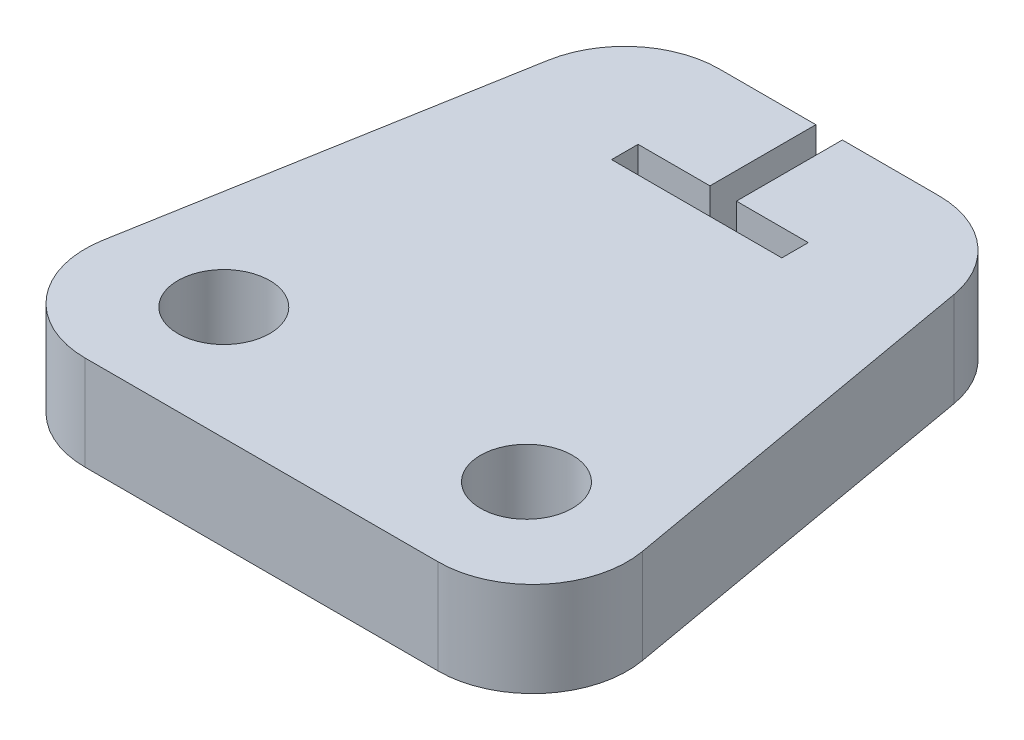
from build123d import *

# Parameters (mm, degrees)
BOSS_EXTRUDE1_DEPTH = 6.35
SKETCH2_R           = 3.0861
CUT_EXTRUDE1_DEPTH  = 7.35
CUT_EXTRUDE2_DEPTH  = 7.35


with BuildPart() as part:
    # Sketch1 → Boss-Extrude1 (new body)
    with BuildSketch(Plane(origin=(0, 0, 0), x_dir=(1, 0, 0), z_dir=(0, 1, 0))):
        with BuildLine():
            Line((-11.850422652, 0), (11.850422652, 0))
            ThreePointArc((11.850422652, 0), (16.714804866, 2.268298678), (18.103951884, 7.452665928))
            Line((18.103951884, 7.452665928), (13.625246574, 32.852665928))
            ThreePointArc((13.625246574, 32.852665928), (11.453418664, 36.614382214), (7.371717342, 38.1))
            Line((7.371717342, 38.1), (-7.371717342, 38.1))
            ThreePointArc((-7.371717342, 38.1), (-11.453418664, 36.614382214), (-13.625246574, 32.852665928))
            Line((-13.625246574, 32.852665928), (-18.103951884, 7.452665928))
            ThreePointArc((-18.103951884, 7.452665928), (-16.714804866, 2.268298678), (-11.850422652, 0))
        make_face()
    extrude(amount=BOSS_EXTRUDE1_DEPTH)

    # Sketch2 → Cut-Extrude1 (cut, through all)
    with BuildSketch(Plane(origin=(0, 6.35, 0), x_dir=(1, 0, 0), z_dir=(0, 1, 0))):
        with Locations((-10.16, 7.62)):
            Circle(SKETCH2_R)
        with Locations((10.16, 7.62)):
            Circle(SKETCH2_R)
    extrude(amount=-CUT_EXTRUDE1_DEPTH, mode=Mode.SUBTRACT)

    # Sketch3 → Cut-Extrude2 (cut, through all)
    with BuildSketch(Plane(origin=(0, 6.35, 0), x_dir=(1, 0, 0), z_dir=(0, 1, 0))):
        Polygon((-0.889, 38.1), (-0.889, 30.988), (-5.715, 30.988), (-5.715, 29.21), (5.715, 29.21), (5.715, 30.988), (0.889, 30.988), (0.889, 38.1), align=None)
    extrude(amount=-CUT_EXTRUDE2_DEPTH, mode=Mode.SUBTRACT)


solid = part.part
